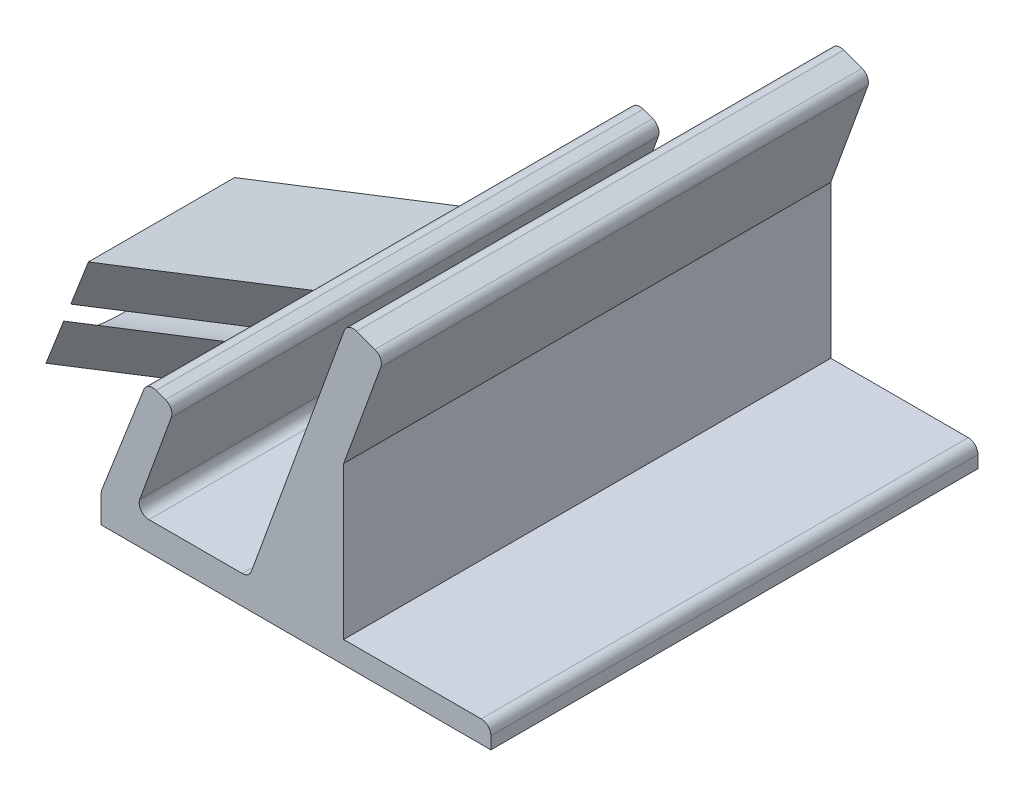
from build123d import *

# Parameters (mm, degrees)
SALIENTE_EXTRUIR1_DEPTH      = 50
SALIENTE_EXTRUIR3_DEPTH      = 1
SALIENTE_EXTRUIR3_DEPTH_BACK = 11
CROQUIS8_R                   = 5.1
CORTAR_EXTRUIR1_DEPTH        = 20


with BuildPart() as part:
    # Croquis1 → Saliente-Extruir1 (new body)
    with BuildSketch(Plane.XY):
        with BuildLine():
            Line((-84.492533904, -6.921751872), (-44.492533904, -6.921751872))
            Line((-44.492533904, -6.921751872), (-44.492533904, -5.660932217))
            ThreePointArc((-44.492533904, -5.660932217), (-44.785427123, -4.953825435), (-45.492533904, -4.660932217))
            Line((-45.492533904, -4.660932217), (-59.602097354, -4.660932217))
            Line((-59.602097354, -4.660932217), (-59.602097354, 10.986403293))
            Line((-59.602097354, 10.986403293), (-55.79772825, 21.438821499))
            ThreePointArc((-55.79772825, 21.438821499), (-55.831113084, 22.203459904), (-56.395400728, 22.720534263))
            Line((-56.395400728, 22.720534263), (-58.274785969, 23.40457455))
            ThreePointArc((-58.274785969, 23.40457455), (-59.039424374, 23.371189716), (-59.556498733, 22.806902073))
            Line((-59.556498733, 22.806902073), (-69.073702494, -3.341400356))
            ThreePointArc((-69.073702494, -3.341400356), (-69.439818678, -3.818532257), (-70.013395115, -3.999380213))
            Line((-70.013395115, -3.999380213), (-79.590995067, -3.999380213))
            ThreePointArc((-79.590995067, -3.999380213), (-80.410147111, -3.572956649), (-80.530687688, -2.657360069))
            Line((-80.530687688, -2.657360069), (-77.297371662, 6.226102703))
            ThreePointArc((-77.297371662, 6.226102703), (-77.330756495, 6.990741108), (-77.895044139, 7.507815467))
            Line((-77.895044139, 7.507815467), (-78.855503706, 7.857394161))
            ThreePointArc((-78.855503706, 7.857394161), (-79.609989894, 7.828674516), (-80.129339821, 7.280632657))
            Line((-80.129339821, 7.280632657), (-84.424349875, -3.746691195))
            ThreePointArc((-84.424349875, -3.746691195), (-84.475340083, -3.924982082), (-84.492533904, -4.109622312))
            Line((-84.492533904, -4.109622312), (-84.492533904, -6.921751872))
        make_face()
    extrude(amount=SALIENTE_EXTRUIR1_DEPTH)

    # Croquis5 → Saliente-Extruir3 (add, two sides)
    with BuildSketch(Plane(origin=(-12.054515952, -30.949648451, 0), x_dir=(0, 0, 1), z_dir=(-0.362931117, -0.931815971, 0))) as saliente_extruir3_sk:
        Polygon((17.5, 77.308166751), (30.522755533, 88.235556115), (45.522755533, 88.235556115), (32.5, 77.308166751), align=None)
    extrude(amount=SALIENTE_EXTRUIR3_DEPTH)
    extrude(saliente_extruir3_sk.sketch, amount=-SALIENTE_EXTRUIR3_DEPTH_BACK)

    # Croquis8 → Cortar-Extruir1 (cut)
    with BuildSketch(Plane(origin=(-54.858231018, 21.366621399, 70.161379414), x_dir=(0.800779124, 0.174492436, 0.572979218), z_dir=(-0.598959761, 0.233287625, 0.766044443))):
        with Locations((-51.412419204, -5.511649837)):
            Circle(CROQUIS8_R)
    extrude(amount=-CORTAR_EXTRUIR1_DEPTH, mode=Mode.SUBTRACT)


solid = part.part
